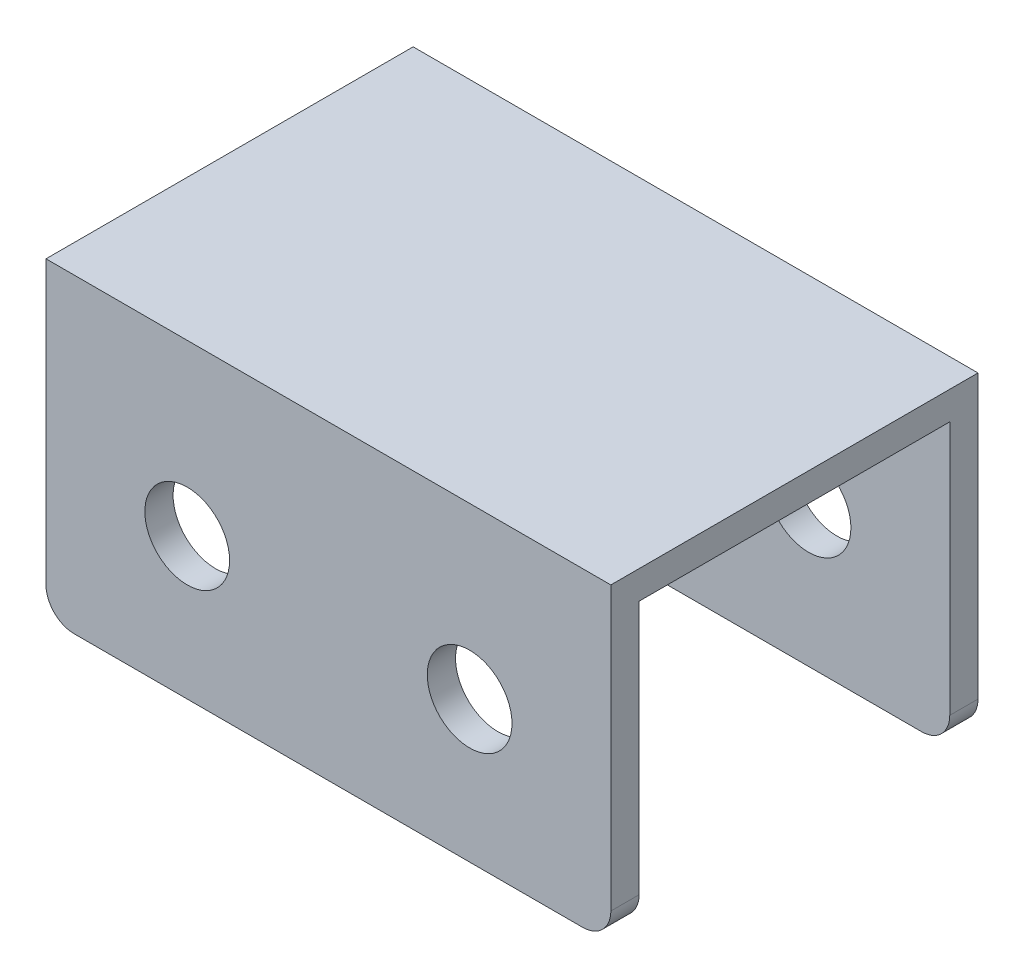
from build123d import *

# Parameters (mm, degrees)
EXTRUDE_THIN1_DEPTH     = 50
SKETCH2_R               = 7.5
CUT_EXTRUDE1_DEPTH      = 33.5
CUT_EXTRUDE1_DEPTH_BACK = 33.5
FILLET1_R               = 5


with BuildPart() as part:
    # Sketch1 → Extrude-Thin1 (new body, symmetric)
    with BuildSketch(Plane(origin=(0, 0, 0), x_dir=(0, 0, -1), z_dir=(1, 0, 0))):
        Polygon((-27.5, -50), (-27.5, 0), (27.5, 0), (27.5, -50), (32.5, -50), (32.5, 5), (-32.5, 5), (-32.5, -50), align=None)
    extrude(amount=EXTRUDE_THIN1_DEPTH, both=True)

    # Sketch2 → Cut-Extrude1 (cut, two sides)
    with BuildSketch(Plane.XY) as cut_extrude1_sk:
        with Locations((-25, -25)):
            Circle(SKETCH2_R)
        with Locations((25, -25)):
            Circle(SKETCH2_R)
    extrude(amount=CUT_EXTRUDE1_DEPTH, mode=Mode.SUBTRACT)
    extrude(cut_extrude1_sk.sketch, amount=-CUT_EXTRUDE1_DEPTH_BACK, mode=Mode.SUBTRACT)

    # Fillet1
    fillet1_edges = [part.edges().sort_by_distance(p)[0] for p in [
        (50, -50, 30),
        (50, -50, -30),
        (-50, -50, 30),
        (-50, -50, -30),
    ]]
    fillet(fillet1_edges, radius=FILLET1_R)


solid = part.part
